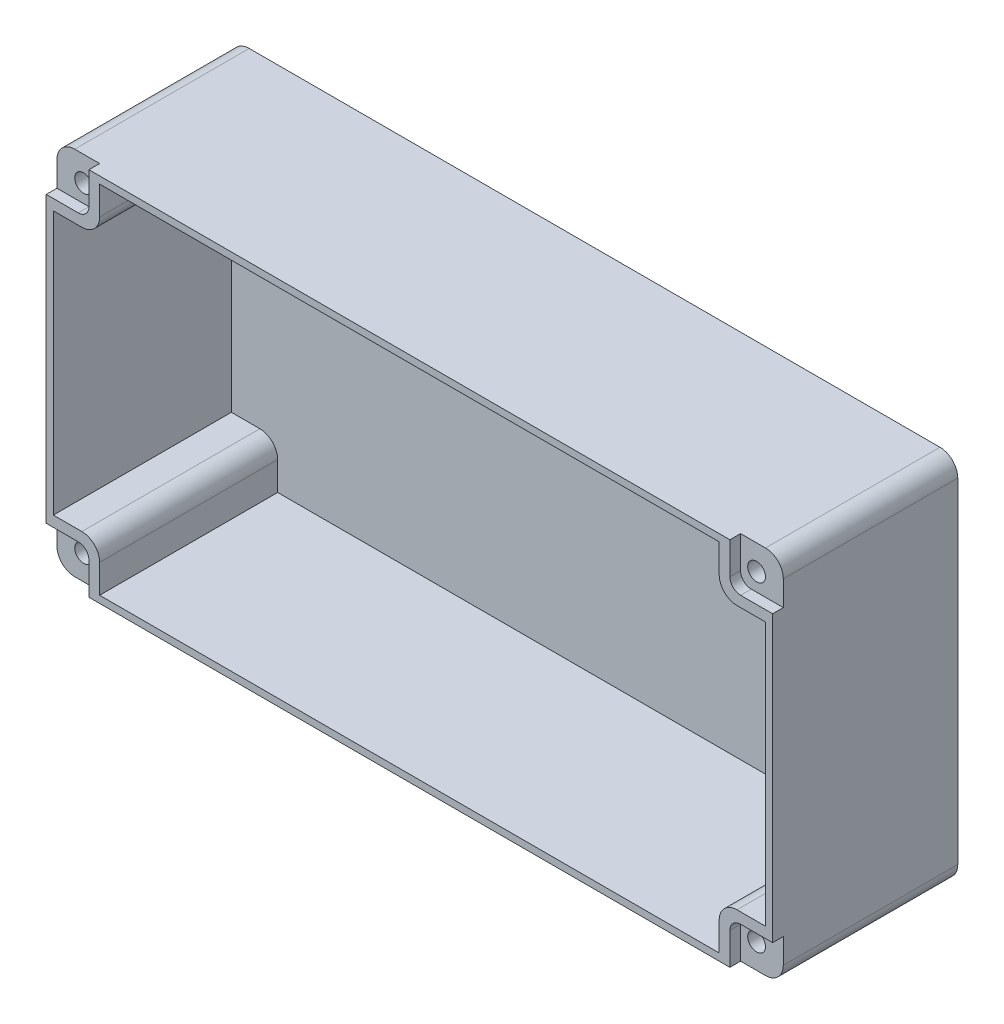
from build123d import *

# Parameters (mm, degrees)
ESBO_O1_W                 = 204
ESBO_O1_H                 = 104
RESSALTO_EXTRUS_O1_DEPTH  = 52
CORTE_EXTRUS_O1_DEPTH     = 50
FILETE1_R                 = 5
CORTE_EXTRUS_O2_DEPTH     = 40
CORTE_EXTRUS_O5_DEPTH     = 3
CORTE_EXTRUS_O6_START     = -53
ESBO_O8_R                 = 2.5
CORTE_EXTRUS_O6_DEPTH     = 54
ESPELHAR2_COPY_1_DEPTH    = 40
ESPELHAR2_COPY_2_DEPTH    = 3
ESPELHAR2_START           = -53
ESPELHAR2_COPY_3_SKETCH_R = 2.5
ESPELHAR2_COPY_3_DEPTH    = 54


with BuildPart() as part:
    # Esboço1 → Ressalto-extrusão1 (new body)
    with BuildSketch(Plane.XY):
        Rectangle(ESBO_O1_W, ESBO_O1_H)
    extrude(amount=-RESSALTO_EXTRUS_O1_DEPTH)

    # Esboço2 → Corte-extrusão1 (cut)
    with BuildSketch(Plane.XY):
        with BuildLine():
            Line((-87, 50), (87, 50))
            Line((87, 50), (87, 42))
            ThreePointArc((87, 42), (88.464466094, 38.464466094), (92, 37))
            Line((92, 37), (100, 37))
            Line((100, 37), (100, -37))
            Line((100, -37), (92, -37))
            ThreePointArc((92, -37), (88.464466094, -38.464466094), (87, -42))
            Line((87, -42), (87, -50))
            Line((87, -50), (-87, -50))
            Line((-87, -50), (-87, -42))
            ThreePointArc((-87, -42), (-88.464466094, -38.464466094), (-92, -37))
            Line((-92, -37), (-100, -37))
            Line((-100, -37), (-100, 37))
            Line((-100, 37), (-92, 37))
            ThreePointArc((-92, 37), (-88.464466094, 38.464466094), (-87, 42))
            Line((-87, 42), (-87, 50))
        make_face()
    extrude(amount=-CORTE_EXTRUS_O1_DEPTH, mode=Mode.SUBTRACT)

    # Filete1
    filete1_edges = [part.edges().sort_by_distance(p)[0] for p in [
        (102, -52, -26),
        (-102, -52, -26),
        (-102, 52, -26),
        (102, 52, -26),
    ]]
    fillet(filete1_edges, radius=FILETE1_R)

    # Esboço4 → Corte-extrusão2 (cut)
    with BuildSketch(Plane(origin=(0, 0, -52), x_dir=(-1, 0, 0), z_dir=(0, 0, -1))):
        with BuildLine():
            Line((-97, 50), (-90, 50))
            Line((-90, 50), (-90, 43))
            ThreePointArc((-90, 43), (-90.878679656, 40.878679656), (-93, 40))
            Line((-93, 40), (-100, 40))
            Line((-100, 40), (-100, 47))
            ThreePointArc((-100, 47), (-99.121320344, 49.121320344), (-97, 50))
        make_face()
    corte_extrus_o2 = extrude(amount=-CORTE_EXTRUS_O2_DEPTH, mode=Mode.SUBTRACT)

    # Esboço7 → Corte-extrusão5 (cut)
    with BuildSketch(Plane.XY):
        with BuildLine():
            Line((-102, 40), (-93, 40))
            ThreePointArc((-93, 40), (-90.878679656, 40.878679656), (-90, 43))
            Line((-90, 43), (-90, 52))
            Line((-90, 52), (-97, 52))
            ThreePointArc((-97, 52), (-100.535533906, 50.535533906), (-102, 47))
            Line((-102, 47), (-102, 40))
        make_face()
    corte_extrus_o5 = extrude(amount=-CORTE_EXTRUS_O5_DEPTH, mode=Mode.SUBTRACT)

    # Esboço8 → Corte-extrusão6 (cut)
    with BuildSketch(Plane.XY.offset(CORTE_EXTRUS_O6_START)):
        with Locations((-94.5, 45)):
            Circle(ESBO_O8_R)
    corte_extrus_o6 = extrude(amount=CORTE_EXTRUS_O6_DEPTH, mode=Mode.SUBTRACT)

    # Espelhar1: Corte-extrusão2, Corte-extrusão5, Corte-extrusão6 across plane
    add(corte_extrus_o2.mirror(Plane(origin=(0, 0, 0), x_dir=(0, 0, 1), z_dir=(1, 0, 0))), mode=Mode.SUBTRACT)
    add(corte_extrus_o5.mirror(Plane(origin=(0, 0, 0), x_dir=(0, 0, 1), z_dir=(1, 0, 0))), mode=Mode.SUBTRACT)
    add(corte_extrus_o6.mirror(Plane(origin=(0, 0, 0), x_dir=(0, 0, 1), z_dir=(1, 0, 0))), mode=Mode.SUBTRACT)

    # Espelhar2: Corte-extrusão2, Corte-extrusão5, Corte-extrusão6 across plane
    add(corte_extrus_o2.mirror(Plane.ZX), mode=Mode.SUBTRACT)
    add(corte_extrus_o5.mirror(Plane.ZX), mode=Mode.SUBTRACT)
    add(corte_extrus_o6.mirror(Plane.ZX), mode=Mode.SUBTRACT)

    # Espelhar2 copy 1 sketch → Espelhar2 copy 1 (cut)
    with BuildSketch(Plane(origin=(0, 0, -52), x_dir=(1, 0, 0), z_dir=(0, 0, -1))):
        with BuildLine():
            Line((-97, 50), (-90, 50))
            Line((-90, 50), (-90, 43))
            ThreePointArc((-90, 43), (-90.878679656, 40.878679656), (-93, 40))
            Line((-93, 40), (-100, 40))
            Line((-100, 40), (-100, 47))
            ThreePointArc((-100, 47), (-99.121320344, 49.121320344), (-97, 50))
        make_face()
    extrude(amount=-ESPELHAR2_COPY_1_DEPTH, mode=Mode.SUBTRACT)

    # Espelhar2 copy 2 sketch → Espelhar2 copy 2 (cut)
    with BuildSketch(Plane(origin=(0, 0, 0), x_dir=(-1, 0, 0), z_dir=(0, 0, 1))):
        with BuildLine():
            Line((-102, 40), (-93, 40))
            ThreePointArc((-93, 40), (-90.878679656, 40.878679656), (-90, 43))
            Line((-90, 43), (-90, 52))
            Line((-90, 52), (-97, 52))
            ThreePointArc((-97, 52), (-100.535533906, 50.535533906), (-102, 47))
            Line((-102, 47), (-102, 40))
        make_face()
    extrude(amount=-ESPELHAR2_COPY_2_DEPTH, mode=Mode.SUBTRACT)

    # Espelhar2 copy 3 sketch → Espelhar2 copy 3 (cut)
    with BuildSketch(Plane(origin=(0, 0, 0), x_dir=(-1, 0, 0), z_dir=(0, 0, 1)).offset(ESPELHAR2_START)):
        with Locations((-94.5, 45)):
            Circle(ESPELHAR2_COPY_3_SKETCH_R)
    extrude(amount=ESPELHAR2_COPY_3_DEPTH, mode=Mode.SUBTRACT)


solid = part.part
